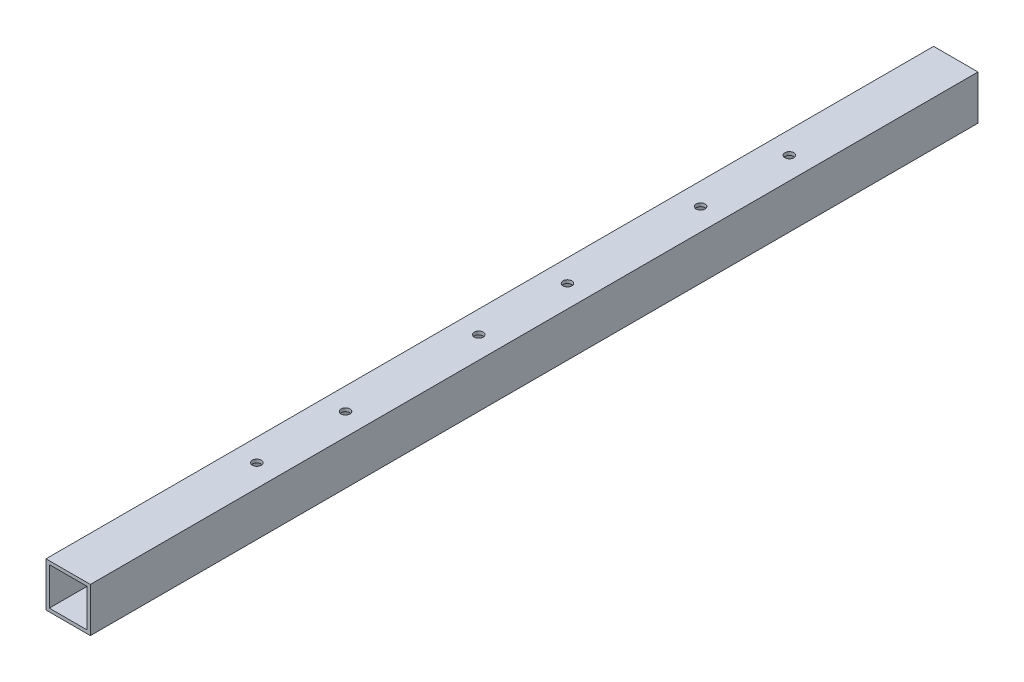
from build123d import *

# Parameters (mm, degrees)
SKETCH1_W           = 20
SKETCH1_H           = 20
BOSS_EXTRUDE1_DEPTH = 400
SKETCH2_W           = 17
SKETCH2_H           = 17
CUT_EXTRUDE1_DEPTH  = 400
SKETCH3_R           = 2
CUT_EXTRUDE2_DEPTH  = 25
SKETCH4_R           = 2
CUT_EXTRUDE3_DEPTH  = 25
LPATTERN1_COUNT     = 3
LPATTERN1_PITCH     = 100


with BuildPart() as part:
    # Sketch1 → Boss-Extrude1 (new body)
    with BuildSketch(Plane.XY):
        Rectangle(SKETCH1_W, SKETCH1_H)
    extrude(amount=BOSS_EXTRUDE1_DEPTH)

    # Sketch2 → Cut-Extrude1 (cut)
    with BuildSketch(Plane(origin=(0, 0, 0), x_dir=(-1, 0, 0), z_dir=(0, 0, -1))):
        Rectangle(SKETCH2_W, SKETCH2_H)
    extrude(amount=-CUT_EXTRUDE1_DEPTH, mode=Mode.SUBTRACT)

    # Sketch3 → Cut-Extrude2 (cut)
    with BuildSketch(Plane(origin=(0, 10, 0), x_dir=(1, 0, 0), z_dir=(0, 1, 0))):
        with Locations((0, -75)):
            Circle(SKETCH3_R)
    cut_extrude2 = extrude(amount=-CUT_EXTRUDE2_DEPTH, mode=Mode.SUBTRACT)

    # Sketch4 → Cut-Extrude3 (cut)
    with BuildSketch(Plane(origin=(0, 10, 0), x_dir=(1, 0, 0), z_dir=(0, 1, 0))):
        with Locations((0, -115)):
            Circle(SKETCH4_R)
    cut_extrude3 = extrude(amount=-CUT_EXTRUDE3_DEPTH, mode=Mode.SUBTRACT)

    # LPattern1: Cut-Extrude2, Cut-Extrude3 ×3
    with Locations(*[(0, 0, i * LPATTERN1_PITCH) for i in range(1, LPATTERN1_COUNT)]):
        add(cut_extrude2, mode=Mode.SUBTRACT)
        add(cut_extrude3, mode=Mode.SUBTRACT)


solid = part.part
